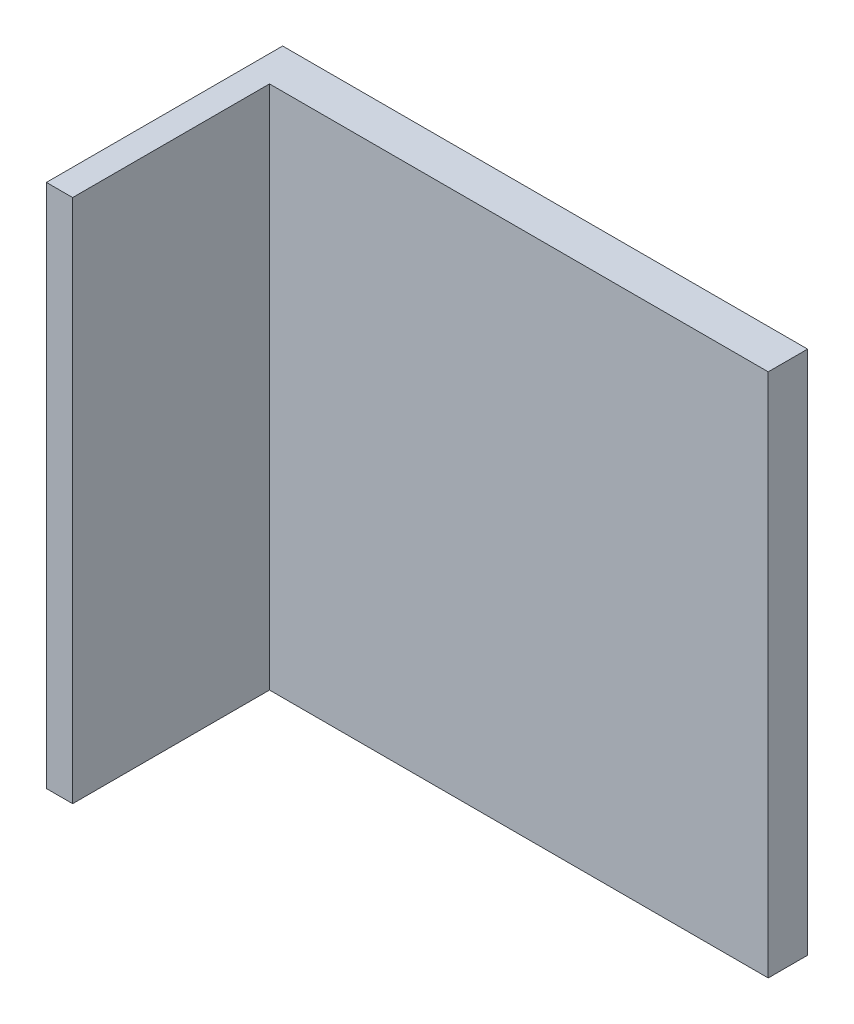
from build123d import *

# Parameters (mm, degrees)
SKETCH3_W           = 200
SKETCH3_H           = 200
BOSS_EXTRUDE1_DEPTH = 15
SKETCH4_W           = 10
SKETCH4_H           = 200
BOSS_EXTRUDE2_DEPTH = 75


with BuildPart() as part:
    # Sketch3 → Boss-Extrude1 (new body)
    with BuildSketch(Plane.XY):
        with Locations((25, 50)):
            Rectangle(SKETCH3_W, SKETCH3_H)
    extrude(amount=BOSS_EXTRUDE1_DEPTH)

    # Sketch4 → Boss-Extrude2 (add)
    with BuildSketch(Plane.XY.offset(15)):
        with Locations((-70, 50)):
            Rectangle(SKETCH4_W, SKETCH4_H)
    extrude(amount=BOSS_EXTRUDE2_DEPTH)


solid = part.part
